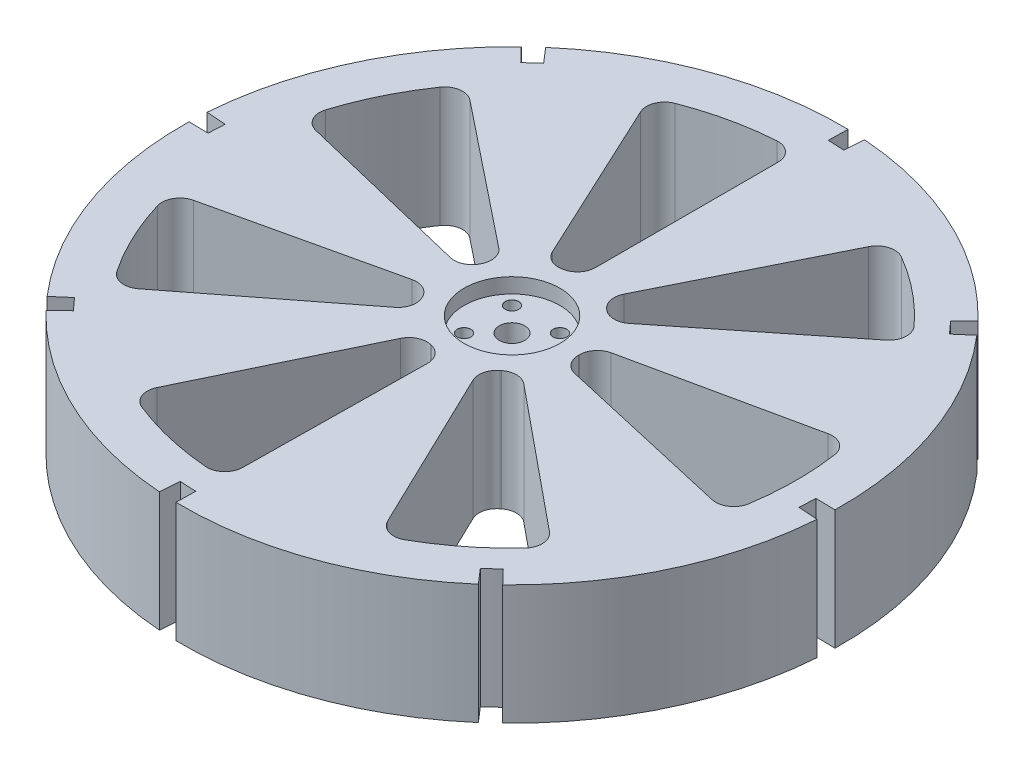
from build123d import *

# Parameters (mm, degrees)
SKETCH1_R                      = 110
BOSS_EXTRUDE1_DEPTH            = 40
CUT_EXTRUDE1_DEPTH             = 40
FILLET1_R                      = 6
SKETCH3_R                      = 4.25
CUT_EXTRUDE2_DEPTH             = 40
CIRPATTERN1_COUNT              = 7
FILLET1_OF_CIRPATTERN1_R       = 6
SKETCH4_R                      = 16
CUT_EXTRUDE3_DEPTH             = 5
M4_CLEARANCE_HOLE1_D           = 4.5
M4_CLEARANCE_HOLE1_DEPTH       = 13
M4_CLEARANCE_HOLE1_CSINK_D     = 4.55
M4_CLEARANCE_HOLE1_CSINK_ANGLE = 90
M4_CLEARANCE_HOLE1_TIP         = 1.351936393
CUT_EXTRUDE4_DEPTH             = 41
CIRPATTERN2_COUNT              = 8


with BuildPart() as part:
    # Sketch1 → Boss-Extrude1 (new body)
    with BuildSketch(Plane(origin=(0, 0, 0), x_dir=(1, 0, 0), z_dir=(0, 1, 0))):
        Circle(SKETCH1_R)
    extrude(amount=BOSS_EXTRUDE1_DEPTH)

    # Sketch2 → Cut-Extrude1 (cut)
    with BuildSketch(Plane(origin=(0, 40, 0), x_dir=(1, 0, 0), z_dir=(0, 1, 0))):
        with BuildLine():
            ThreePointArc((-9.508910889, 20.391925208), (-4.869891314, 21.96666016), (0, 22.5))
            Line((0, 22.5), (0, 95))
            ThreePointArc((0, 95), (-20.561763324, 92.748120676), (-40.148734865, 86.099239768))
            Line((-40.148734865, 86.099239768), (-9.508910889, 20.391925208))
        make_face()
    cut_extrude1 = extrude(amount=-CUT_EXTRUDE1_DEPTH, mode=Mode.SUBTRACT)

    # Fillet1
    fillet1_edges = [part.edges().sort_by_distance(p)[0] for p in [
        (0, 20, -22.5),
        (-9.508910889, 20, -20.391925208),
        (-40.148734865, 20, -86.099239768),
        (0, 20, -95),
    ]]
    fillet(fillet1_edges, radius=FILLET1_R)

    # Sketch3 → Cut-Extrude2 (cut)
    with BuildSketch(Plane(origin=(0, 40, 0), x_dir=(1, 0, 0), z_dir=(0, 1, 0))):
        Circle(SKETCH3_R)
    extrude(amount=-CUT_EXTRUDE2_DEPTH, mode=Mode.SUBTRACT)

    # CirPattern1: Cut-Extrude1 ×7 about axis
    cirpattern1_axis = Axis((0, 0, 0), (0, 1, 0))
    for i in range(1, CIRPATTERN1_COUNT):
        add(cut_extrude1.rotate(cirpattern1_axis, i * 360 / CIRPATTERN1_COUNT), mode=Mode.SUBTRACT)

    # Fillet1 of CirPattern1
    fillet1_of_cirpattern1_edges = [part.edges().sort_by_distance(p)[0] for p in [
        (-17.591208356, 20, -14.028520542),
        (-21.871758082, 20, -5.279791511),
        (-92.347423014, 20, -22.292453044),
        (-74.273990834, 20, -59.231531177),
        (-21.935878024, 20, 5.006721014),
        (-17.764725337, 20, 13.808132883),
        (-75.006618089, 20, 58.301005505),
        (-92.618151657, 20, 21.139488726),
        (-9.76238413, 20, 20.271799528),
        (-0.280492078, 20, 22.498251581),
        (-1.184299887, 20, 94.992617786),
        (-41.218955216, 20, 85.592042451),
        (9.76238413, 20, 20.271799528),
        (17.414957436, 20, 14.246727958),
        (73.529820285, 20, 60.152851377),
        (41.218955216, 20, 85.592042451),
        (21.935878024, 20, 5.006721014),
        (21.996588801, 20, -4.732872398),
        (92.874486047, 20, -19.983239013),
        (92.618151657, 20, 21.139488726),
        (17.591208356, 20, -14.028520542),
        (10.01434015, 20, -20.148523305),
        (42.282769521, 20, -85.071542842),
        (74.273990834, 20, -59.231531177),
    ]]
    fillet(fillet1_of_cirpattern1_edges, radius=FILLET1_OF_CIRPATTERN1_R)

    # Sketch4 → Cut-Extrude3 (cut)
    with BuildSketch(Plane(origin=(0, 40, 0), x_dir=(1, 0, 0), z_dir=(0, 1, 0))):
        Circle(SKETCH4_R)
    extrude(amount=-CUT_EXTRUDE3_DEPTH, mode=Mode.SUBTRACT)

    # M4 Clearance Hole1
    with Locations(Plane(origin=(0, 35, 0), x_dir=(1, 0, 0), z_dir=(0, 1, 0))):
        with Locations((8, 8), (-8, 8), (-8, -8), (8, -8)):
            CounterSinkHole(M4_CLEARANCE_HOLE1_D / 2, M4_CLEARANCE_HOLE1_CSINK_D / 2, depth=M4_CLEARANCE_HOLE1_DEPTH, counter_sink_angle=M4_CLEARANCE_HOLE1_CSINK_ANGLE)
            with Locations((0, 0, -(M4_CLEARANCE_HOLE1_DEPTH + M4_CLEARANCE_HOLE1_TIP / 2))):  # 118° drill point
                Cone(0, M4_CLEARANCE_HOLE1_D / 2, M4_CLEARANCE_HOLE1_TIP, mode=Mode.SUBTRACT)

    # Sketch10 → Cut-Extrude4 (cut, through all)
    with BuildSketch(Plane(origin=(0, 40, 0), x_dir=(1, 0, 0), z_dir=(0, 1, 0))):
        with BuildLine():
            ThreePointArc((2.060734507, 103.479482862), (4.768805418, 103.390079287), (7.473608029, 103.229817316))
            Line((7.473608029, 103.229817316), (7.942965055, 109.712849321))
            ThreePointArc((7.942965055, 109.712849321), (5.068295614, 109.883176053), (2.190152616, 109.978194346))
            Line((2.190152616, 109.978194346), (2.060734507, 103.479482862))
        make_face()
    cut_extrude4 = extrude(amount=-CUT_EXTRUDE4_DEPTH, mode=Mode.SUBTRACT)

    # CirPattern2: Cut-Extrude4 ×8 about axis
    cirpattern2_axis = Axis((0, 0, 0), (0, 1, 0))
    for i in range(1, CIRPATTERN2_COUNT):
        add(cut_extrude4.rotate(cirpattern2_axis, i * 360 / CIRPATTERN2_COUNT), mode=Mode.SUBTRACT)


solid = part.part
